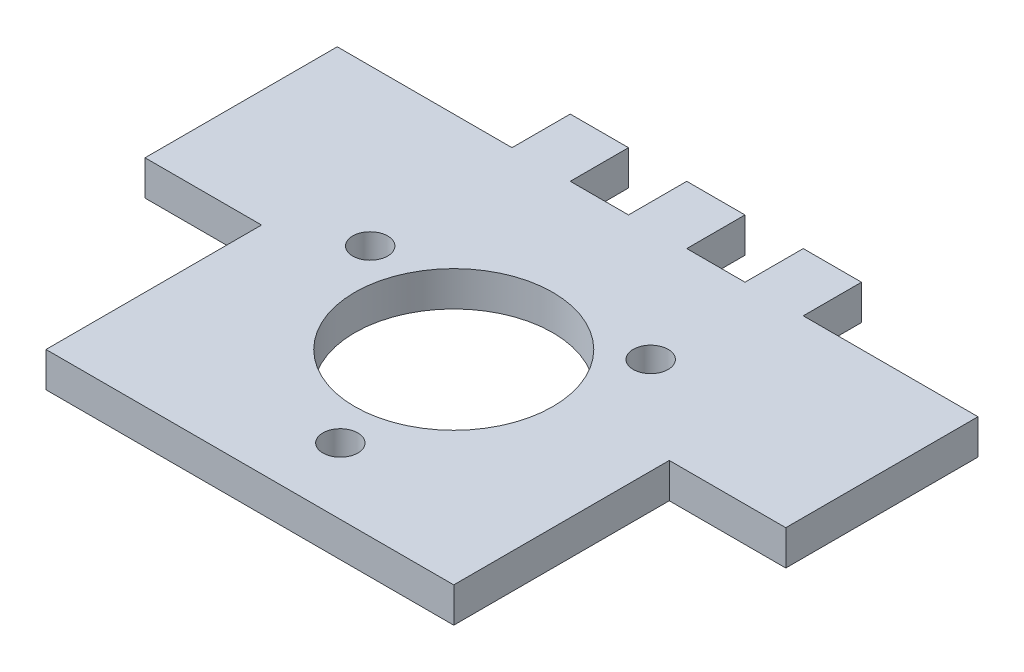
from build123d import *

# Parameters (mm, degrees)
ESQUISSE1_W                = 35
ESQUISSE1_H                = 35
BOSS_EXTRU_1_DEPTH         = 3
ESQUISSE2_W                = 5
ESQUISSE2_H                = 5
BOSS_EXTRU_2_DEPTH         = 3
R_P_TITION_LIN_AIRE1_COUNT = 3
R_P_TITION_LIN_AIRE1_PITCH = 10
ESQUISSE3_R                = 8.5
ESQUISSE3_R_2              = 1.5
ENL_V_MAT_EXTRU_1_DEPTH    = 5
ESQUISSE4_W                = 10
ESQUISSE4_H                = 16.5
BOSS_EXTRU_3_DEPTH         = 3


with BuildPart() as part:
    # Esquisse1 → Boss.-Extru.1 (new body)
    with BuildSketch(Plane(origin=(0, 0, 0), x_dir=(1, 0, 0), z_dir=(0, 1, 0))):
        Rectangle(ESQUISSE1_W, ESQUISSE1_H)
    extrude(amount=BOSS_EXTRU_1_DEPTH)

    # Esquisse2 → Boss.-Extru.2 (add)
    with BuildSketch(Plane(origin=(0, 3, 0), x_dir=(1, 0, 0), z_dir=(0, 1, 0))):
        with Locations((-10, 20)):
            Rectangle(ESQUISSE2_W, ESQUISSE2_H)
    boss_extru_2 = extrude(amount=-BOSS_EXTRU_2_DEPTH)

    # Répétition linéaire1: Boss.-Extru.2 ×3
    with Locations(*[(i * R_P_TITION_LIN_AIRE1_PITCH, 0, 0) for i in range(1, R_P_TITION_LIN_AIRE1_COUNT)]):
        add(boss_extru_2)

    # Esquisse3 → Enlèv. mat.-Extru.1 (cut)
    with BuildSketch(Plane(origin=(0, 3, 0), x_dir=(1, 0, 0), z_dir=(0, 1, 0))):
        Circle(ESQUISSE3_R)
        with Locations((2.083778132, -11.817693036)):
            Circle(ESQUISSE3_R_2)
        with Locations((-11.276311449, 4.10424172)):
            Circle(ESQUISSE3_R_2)
        with Locations((9.192533317, 7.713451316)):
            Circle(ESQUISSE3_R_2)
    extrude(amount=-ENL_V_MAT_EXTRU_1_DEPTH, mode=Mode.SUBTRACT)

    # Esquisse4 → Boss.-Extru.3 (add)
    with BuildSketch(Plane(origin=(0, 3, 0), x_dir=(1, 0, 0), z_dir=(0, 1, 0))):
        with Locations((-22.5, 9.25)):
            Rectangle(ESQUISSE4_W, ESQUISSE4_H)
    boss_extru_3 = extrude(amount=-BOSS_EXTRU_3_DEPTH)

    # Symétrie1: Boss.-Extru.3 across plane
    add(boss_extru_3.mirror(Plane(origin=(0, 0, 0), x_dir=(0, 0, 1), z_dir=(1, 0, 0))))


solid = part.part
